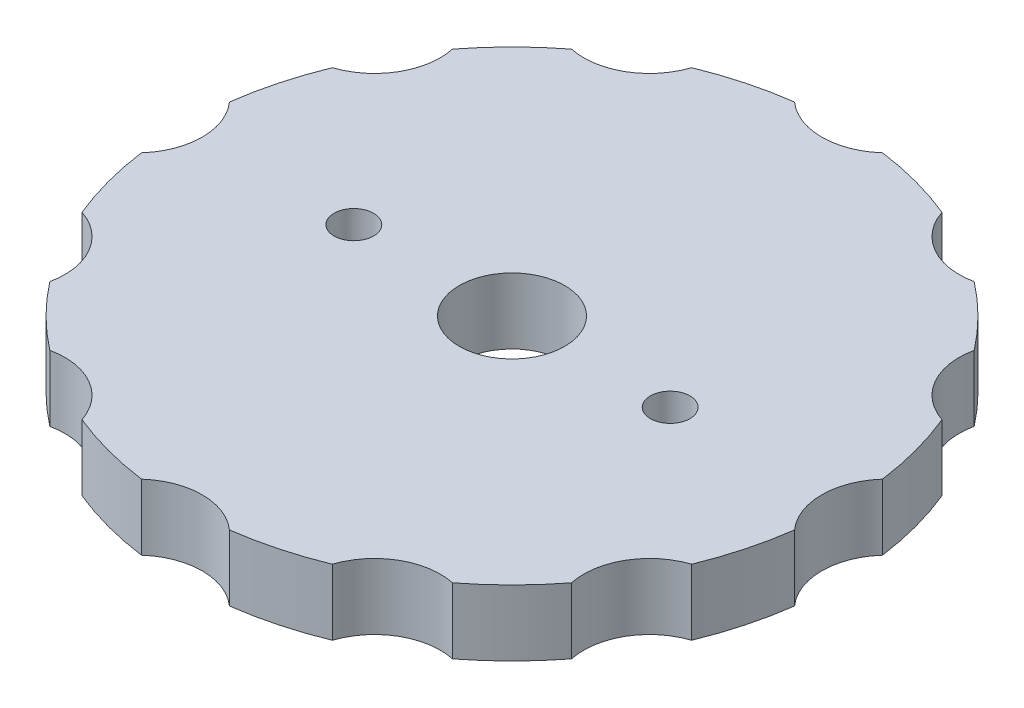
from build123d import *

# Parameters (mm, degrees)
SKETCH1_R           = 25
BOSS_EXTRUDE1_DEPTH = 5
SKETCH2_R           = 5
CUT_EXTRUDE1_DEPTH  = 6
CIRPATTERN1_COUNT   = 12
SKETCH3_R           = 4
CUT_EXTRUDE2_DEPTH  = 6
SKETCH4_R           = 1.5
CUT_EXTRUDE3_DEPTH  = 6


with BuildPart() as part:
    # Sketch1 → Boss-Extrude1 (new body)
    with BuildSketch(Plane(origin=(0, 0, 0), x_dir=(1, 0, 0), z_dir=(0, 1, 0))):
        Circle(SKETCH1_R)
    extrude(amount=BOSS_EXTRUDE1_DEPTH)

    # Sketch2 → Cut-Extrude1 (cut, through all)
    with BuildSketch(Plane(origin=(0, 0, 0), x_dir=(1, 0, 0), z_dir=(0, 1, 0))):
        with Locations((0, 28.5)):
            Circle(SKETCH2_R)
    cut_extrude1 = extrude(amount=CUT_EXTRUDE1_DEPTH, mode=Mode.SUBTRACT)

    # CirPattern1: Cut-Extrude1 ×12 about axis
    cirpattern1_axis = Axis((0, 0, 0), (0, 1, 0))
    for i in range(1, CIRPATTERN1_COUNT):
        add(cut_extrude1.rotate(cirpattern1_axis, i * 360 / CIRPATTERN1_COUNT), mode=Mode.SUBTRACT)

    # Sketch3 → Cut-Extrude2 (cut, through all)
    with BuildSketch(Plane(origin=(0, 0, 0), x_dir=(1, 0, 0), z_dir=(0, 1, 0))):
        Circle(SKETCH3_R)
    extrude(amount=CUT_EXTRUDE2_DEPTH, mode=Mode.SUBTRACT)

    # Sketch4 → Cut-Extrude3 (cut, through all)
    with BuildSketch(Plane(origin=(0, 5, 0), x_dir=(1, 0, 0), z_dir=(0, 1, 0))):
        with Locations((-12, 0)):
            Circle(SKETCH4_R)
        with Locations((12, 0)):
            Circle(SKETCH4_R)
    extrude(amount=-CUT_EXTRUDE3_DEPTH, mode=Mode.SUBTRACT)


solid = part.part
